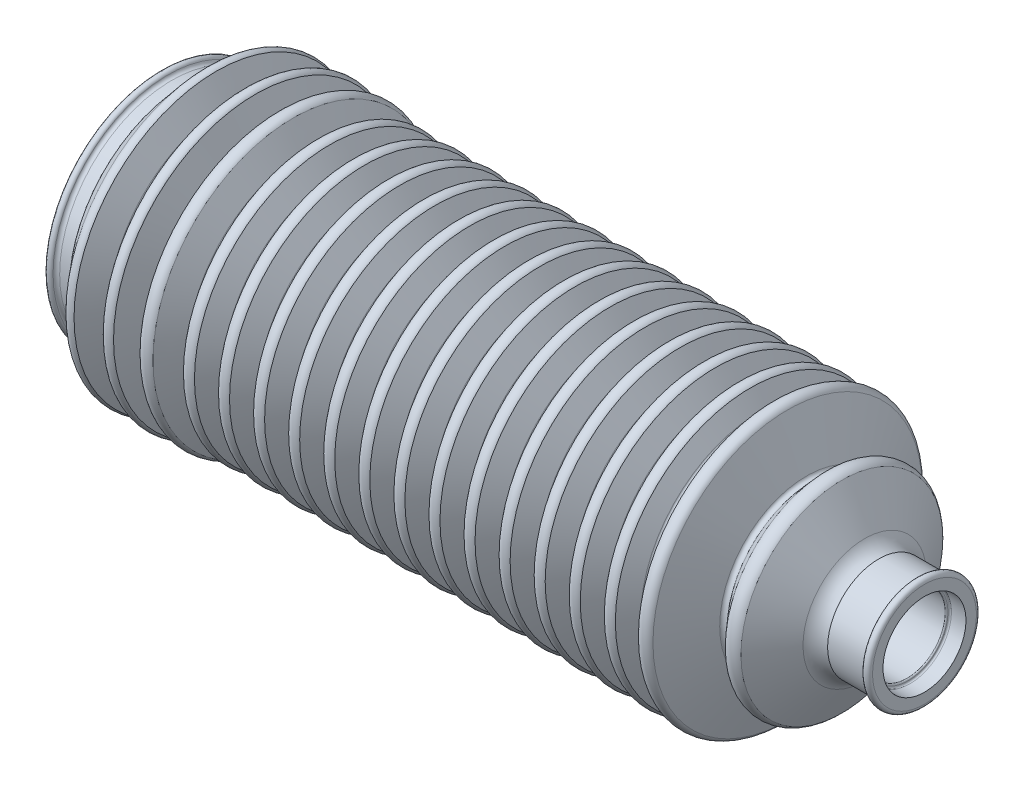
from build123d import *


with BuildPart() as part:
    # Sketch1 → Revolve1 (revolve)
    with BuildSketch(Plane.XY):
        with BuildLine():
            Line((3.221368257, 33.878790712), (7.070248097, 33.878790712))
            ThreePointArc((7.070248097, 33.878790712), (7.405965444, 34.24421048), (7.514879986, 34.728333777))
            ThreePointArc((7.514879986, 34.728333777), (7.607872623, 35.188399878), (7.910695197, 35.54701797))
            Line((7.910695197, 35.54701797), (14.128199866, 42.901667156))
            ThreePointArc((14.128199866, 42.901667156), (15.378285644, 43.439146592), (16.653883195, 42.965385594))
            Line((16.653883195, 42.965385594), (20.312234051, 36.183117788))
            ThreePointArc((20.312234051, 36.183117788), (21.171530734, 35.535694554), (22.072250425, 36.124126089))
            Line((22.072250425, 36.124126089), (25.335357267, 42.794036651))
            ThreePointArc((25.335357267, 42.794036651), (26.879403502, 43.602334759), (28.439590983, 42.825649731))
            Line((28.439590983, 42.825649731), (31.467187999, 35.690454559))
            ThreePointArc((31.467187999, 35.690454559), (32.045199163, 35.114483452), (32.729476647, 35.559010105))
            Line((32.729476647, 35.559010105), (36.023922693, 42.40238333))
            ThreePointArc((36.023922693, 42.40238333), (37.946776135, 43.22373671), (39.823559161, 42.301960053))
            Line((39.823559161, 42.301960053), (43.423249266, 35.419160088))
            ThreePointArc((43.423249266, 35.419160088), (43.922008495, 35.046118785), (44.469992045, 35.342150223))
            Line((44.469992045, 35.342150223), (47.301767281, 40.508011955))
            ThreePointArc((47.301767281, 40.508011955), (49.015022223, 41.543439015), (50.888539305, 40.838254332))
            Line((50.888539305, 40.838254332), (54.0154515, 35.419160088))
            ThreePointArc((54.0154515, 35.419160088), (54.514210729, 35.046118785), (55.062194279, 35.342150223))
            Line((55.062194279, 35.342150223), (57.893969515, 40.508011955))
            ThreePointArc((57.893969515, 40.508011955), (59.607224457, 41.543439015), (61.480741539, 40.838254332))
            Line((61.480741539, 40.838254332), (64.607653734, 35.419160088))
            ThreePointArc((64.607653734, 35.419160088), (65.106412963, 35.046118785), (65.654396513, 35.342150223))
            Line((65.654396513, 35.342150223), (68.486171749, 40.508011955))
            ThreePointArc((68.486171749, 40.508011955), (70.199426691, 41.543439015), (72.072943773, 40.838254332))
            Line((72.072943773, 40.838254332), (75.199855968, 35.419160088))
            ThreePointArc((75.199855968, 35.419160088), (75.698615197, 35.046118785), (76.246598747, 35.342150223))
            Line((76.246598747, 35.342150223), (79.078373983, 40.508011955))
            ThreePointArc((79.078373983, 40.508011955), (80.791628925, 41.543439015), (82.665146007, 40.838254332))
            Line((82.665146007, 40.838254332), (85.792058202, 35.419160088))
            ThreePointArc((85.792058202, 35.419160088), (86.290817431, 35.046118785), (86.838800981, 35.342150223))
            Line((86.838800981, 35.342150223), (89.670576217, 40.508011955))
            ThreePointArc((89.670576217, 40.508011955), (91.383831159, 41.543439015), (93.257348241, 40.838254332))
            Line((93.257348241, 40.838254332), (96.384260436, 35.419160088))
            ThreePointArc((96.384260436, 35.419160088), (96.883019665, 35.046118785), (97.431003215, 35.342150223))
            Line((97.431003215, 35.342150223), (100.262778451, 40.508011955))
            ThreePointArc((100.262778451, 40.508011955), (101.976033393, 41.543439015), (103.849550475, 40.838254332))
            Line((103.849550475, 40.838254332), (106.97646267, 35.419160088))
            ThreePointArc((106.97646267, 35.419160088), (107.475221899, 35.046118785), (108.023205449, 35.342150223))
            Line((108.023205449, 35.342150223), (110.854980685, 40.508011955))
            ThreePointArc((110.854980685, 40.508011955), (112.568235627, 41.543439015), (114.441752709, 40.838254332))
            Line((114.441752709, 40.838254332), (117.568664904, 35.419160088))
            ThreePointArc((117.568664904, 35.419160088), (118.067424134, 35.046118785), (118.615407683, 35.342150223))
            Line((118.615407683, 35.342150223), (121.447182919, 40.508011955))
            ThreePointArc((121.447182919, 40.508011955), (123.160437861, 41.543439015), (125.033954943, 40.838254332))
            Line((125.033954943, 40.838254332), (128.160867138, 35.419160088))
            ThreePointArc((128.160867138, 35.419160088), (128.659626368, 35.046118785), (129.207609917, 35.342150223))
            Line((129.207609917, 35.342150223), (132.039385153, 40.508011955))
            ThreePointArc((132.039385153, 40.508011955), (133.752640095, 41.543439015), (135.626157177, 40.838254332))
            Line((135.626157177, 40.838254332), (138.753069372, 35.419160088))
            ThreePointArc((138.753069372, 35.419160088), (139.251828602, 35.046118785), (139.799812151, 35.342150223))
            Line((139.799812151, 35.342150223), (142.631587387, 40.508011955))
            ThreePointArc((142.631587387, 40.508011955), (144.344842329, 41.543439015), (146.218359411, 40.838254332))
            Line((146.218359411, 40.838254332), (149.345271606, 35.419160088))
            ThreePointArc((149.345271606, 35.419160088), (149.844030836, 35.046118785), (150.392014385, 35.342150223))
            Line((150.392014385, 35.342150223), (153.223789621, 40.508011955))
            ThreePointArc((153.223789621, 40.508011955), (154.937044563, 41.543439015), (156.810561645, 40.838254332))
            Line((156.810561645, 40.838254332), (159.93747384, 35.419160088))
            ThreePointArc((159.93747384, 35.419160088), (160.43623307, 35.046118785), (160.984216619, 35.342150223))
            Line((160.984216619, 35.342150223), (163.815991855, 40.508011955))
            ThreePointArc((163.815991855, 40.508011955), (165.529246797, 41.543439015), (167.402763879, 40.838254332))
            Line((167.402763879, 40.838254332), (170.529676074, 35.419160088))
            ThreePointArc((170.529676074, 35.419160088), (171.028435304, 35.046118785), (171.576418853, 35.342150223))
            Line((171.576418853, 35.342150223), (174.408194089, 40.508011955))
            ThreePointArc((174.408194089, 40.508011955), (176.121449031, 41.543439015), (177.994966114, 40.838254332))
            Line((177.994966114, 40.838254332), (180.724704967, 35.921453172))
            ThreePointArc((180.724704967, 35.921453172), (181.409662936, 35.34307592), (182.165094124, 35.825788447))
            Line((182.165094124, 35.825788447), (185.268298993, 41.154370558))
            ThreePointArc((185.268298993, 41.154370558), (187.3417255, 41.879114473), (189.147171924, 40.628229013))
            Line((189.147171924, 40.628229013), (194.910077069, 26.239186748))
            ThreePointArc((194.910077069, 26.239186748), (195.862219067, 25.492926104), (196.937002956, 26.048190838))
            Line((196.937002956, 26.048190838), (201.260627224, 30.897632437))
            ThreePointArc((201.260627224, 30.897632437), (203.496069276, 31.526745102), (205.571152035, 30.484144767))
            Line((205.571152035, 30.484144767), (212.454561714, 18.629433224))
            ThreePointArc((212.454561714, 18.629433224), (214.239264995, 16.595835186), (216.670392203, 15.408271594))
            Line((216.670392203, 15.408271594), (227.906405044, 15.408271594))
            Line((227.906405044, 15.408271594), (228.440482847, 16.518582475))
            ThreePointArc((228.440482847, 16.518582475), (229.76526454, 16.811021759), (230.511663133, 15.678124407))
            Line((230.511663133, 15.678124407), (230.511663133, 12.525747785))
            Line((230.511663133, 12.525747785), (226.114809286, 12.525747785))
            ThreePointArc((226.114809286, 12.525747785), (225.748505907, 12.361847447), (225.612120042, 11.984434698))
            ThreePointArc((225.612120042, 11.984434698), (225.527216939, 11.670316388), (225.249960419, 11.5))
            Line((225.249960419, 11.5), (209.806851065, 11.5))
            ThreePointArc((209.806851065, 11.5), (208.953219419, 12.073669813), (208.905150254, 13.101032162))
            ThreePointArc((208.905150254, 13.101032162), (209.142771961, 13.875408396), (208.93430813, 14.658137887))
            Line((208.93430813, 14.658137887), (203.900074277, 27.656980378))
            ThreePointArc((203.900074277, 27.656980378), (203.123612207, 28.397590223), (202.097354108, 28.084236423))
            Line((202.097354108, 28.084236423), (198.97375442, 23.721481331))
            ThreePointArc((198.97375442, 23.721481331), (196.45467261, 22.356632248), (193.795349791, 23.422741213))
            Line((193.795349791, 23.422741213), (187.385999728, 38.061664586))
            ThreePointArc((187.385999728, 38.061664586), (186.782123925, 38.500140631), (186.169122231, 38.074516205))
            Line((186.169122231, 38.074516205), (183.963782955, 33.682218081))
            ThreePointArc((183.963782955, 33.682218081), (181.812879066, 32.28046912), (179.460933559, 33.309857297))
            Line((179.460933559, 33.309857297), (177.061299996, 38.496324327))
            ThreePointArc((177.061299996, 38.496324327), (176.391844722, 38.9017234), (175.760633226, 38.439023908))
            Line((175.760633226, 38.439023908), (172.987938862, 33.233406125))
            ThreePointArc((172.987938862, 33.233406125), (171.099614748, 32.28046912), (169.162719512, 33.130347782))
            Line((169.162719512, 33.130347782), (166.469097762, 38.496324327))
            ThreePointArc((166.469097762, 38.496324327), (165.799642488, 38.9017234), (165.168430992, 38.439023908))
            Line((165.168430992, 38.439023908), (162.395736628, 33.233406125))
            ThreePointArc((162.395736628, 33.233406125), (160.507412514, 32.28046912), (158.570517278, 33.130347782))
            Line((158.570517278, 33.130347782), (155.876895528, 38.496324327))
            ThreePointArc((155.876895528, 38.496324327), (155.207440254, 38.9017234), (154.576228758, 38.439023908))
            Line((154.576228758, 38.439023908), (151.803534394, 33.233406125))
            ThreePointArc((151.803534394, 33.233406125), (149.915210279, 32.28046912), (147.978315044, 33.130347782))
            Line((147.978315044, 33.130347782), (145.284693294, 38.496324327))
            ThreePointArc((145.284693294, 38.496324327), (144.61523802, 38.9017234), (143.984026524, 38.439023908))
            Line((143.984026524, 38.439023908), (141.211332159, 33.233406125))
            ThreePointArc((141.211332159, 33.233406125), (139.323008045, 32.28046912), (137.38611281, 33.130347782))
            Line((137.38611281, 33.130347782), (134.69249106, 38.496324327))
            ThreePointArc((134.69249106, 38.496324327), (134.023035786, 38.9017234), (133.39182429, 38.439023908))
            Line((133.39182429, 38.439023908), (130.619129925, 33.233406125))
            ThreePointArc((130.619129925, 33.233406125), (128.730805811, 32.28046912), (126.793910576, 33.130347782))
            Line((126.793910576, 33.130347782), (124.100288826, 38.496324327))
            ThreePointArc((124.100288826, 38.496324327), (123.430833552, 38.9017234), (122.799622056, 38.439023908))
            Line((122.799622056, 38.439023908), (120.026927691, 33.233406125))
            ThreePointArc((120.026927691, 33.233406125), (118.138603577, 32.28046912), (116.201708342, 33.130347782))
            Line((116.201708342, 33.130347782), (113.508086592, 38.496324327))
            ThreePointArc((113.508086592, 38.496324327), (112.838631318, 38.9017234), (112.207419822, 38.439023908))
            Line((112.207419822, 38.439023908), (109.434725457, 33.233406125))
            ThreePointArc((109.434725457, 33.233406125), (107.546401343, 32.28046912), (105.609506108, 33.130347782))
            Line((105.609506108, 33.130347782), (102.915884358, 38.496324327))
            ThreePointArc((102.915884358, 38.496324327), (102.246429084, 38.9017234), (101.615217588, 38.439023908))
            Line((101.615217588, 38.439023908), (98.842523223, 33.233406125))
            ThreePointArc((98.842523223, 33.233406125), (96.954199109, 32.28046912), (95.017303874, 33.130347782))
            Line((95.017303874, 33.130347782), (92.323682124, 38.496324327))
            ThreePointArc((92.323682124, 38.496324327), (91.65422685, 38.9017234), (91.023015354, 38.439023908))
            Line((91.023015354, 38.439023908), (88.250320989, 33.233406125))
            ThreePointArc((88.250320989, 33.233406125), (86.361996875, 32.28046912), (84.425101639, 33.130347782))
            Line((84.425101639, 33.130347782), (81.73147989, 38.496324327))
            ThreePointArc((81.73147989, 38.496324327), (81.062024616, 38.9017234), (80.43081312, 38.439023908))
            Line((80.43081312, 38.439023908), (77.658118755, 33.233406125))
            ThreePointArc((77.658118755, 33.233406125), (75.769794641, 32.28046912), (73.832899405, 33.130347782))
            Line((73.832899405, 33.130347782), (71.139277656, 38.496324327))
            ThreePointArc((71.139277656, 38.496324327), (70.469822382, 38.9017234), (69.838610886, 38.439023908))
            Line((69.838610886, 38.439023908), (67.065916521, 33.233406125))
            ThreePointArc((67.065916521, 33.233406125), (65.177592407, 32.28046912), (63.240697171, 33.130347782))
            Line((63.240697171, 33.130347782), (60.547075422, 38.496324327))
            ThreePointArc((60.547075422, 38.496324327), (59.877620148, 38.9017234), (59.246408652, 38.439023908))
            Line((59.246408652, 38.439023908), (56.473714287, 33.233406125))
            ThreePointArc((56.473714287, 33.233406125), (54.585390173, 32.28046912), (52.648494937, 33.130347782))
            Line((52.648494937, 33.130347782), (49.954873188, 38.496324327))
            ThreePointArc((49.954873188, 38.496324327), (49.285417914, 38.9017234), (48.654206418, 38.439023908))
            Line((48.654206418, 38.439023908), (45.881512053, 33.233406125))
            ThreePointArc((45.881512053, 33.233406125), (43.993187939, 32.28046912), (42.056292703, 33.130347782))
            Line((42.056292703, 33.130347782), (38.561545914, 40.156611946))
            ThreePointArc((38.561545914, 40.156611946), (38.046825968, 40.626060786), (37.44102868, 40.282071711))
            Line((37.44102868, 40.282071711), (34.326209083, 33.358024074))
            ThreePointArc((34.326209083, 33.358024074), (32.365592856, 32.204833554), (30.354572169, 33.267688275))
            Line((30.354572169, 33.267688275), (27.326999018, 40.468812026))
            ThreePointArc((27.326999018, 40.468812026), (26.713995642, 40.860514038), (26.116830024, 40.445066291))
            Line((26.116830024, 40.445066291), (23.533624804, 34.048788923))
            ThreePointArc((23.533624804, 34.048788923), (21.897030245, 32.423628286), (19.679310759, 33.057117929))
            Line((19.679310759, 33.057117929), (15.480230026, 40.513945233))
            ThreePointArc((15.480230026, 40.513945233), (14.995692793, 40.840493429), (14.520372989, 40.50066827))
            Line((14.520372989, 40.50066827), (9.830425619, 31.512453836))
            ThreePointArc((9.830425619, 31.512453836), (9.533086521, 30.857285093), (9.443902196, 30.14335038))
            ThreePointArc((9.443902196, 30.14335038), (9.401686774, 29.198965046), (8.720919478, 28.543067424))
            Line((8.720919478, 28.543067424), (0.995835452, 28.543067424))
            ThreePointArc((0.995835452, 28.543067424), (0.33273406, 28.761978046), (0, 29.375910746))
            Line((0, 29.375910746), (0, 34.20997744))
            ThreePointArc((0, 34.20997744), (0.803635012, 35.359776869), (2.032874614, 34.683878978))
            ThreePointArc((2.032874614, 34.683878978), (2.477095664, 34.059862637), (3.221368257, 33.878790712))
        make_face()
    revolve(axis=Axis((0, 0, 0), (1, 0, 0)))


solid = part.part
